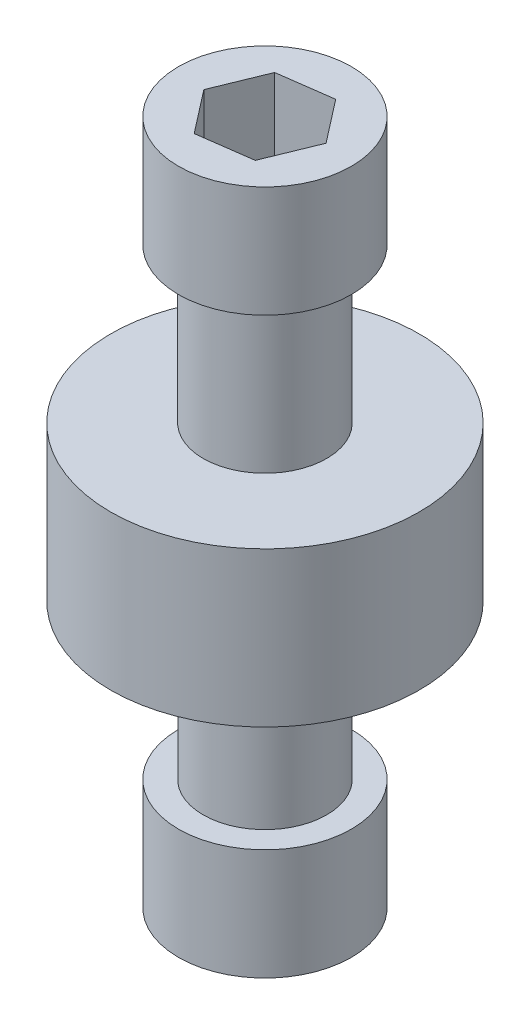
from build123d import *

# Parameters (mm, degrees)
SKETCH1_R           = 6.35
BOSS_EXTRUDE1_DEPTH = 6.35
SKETCH2_R           = 2.54
BOSS_EXTRUDE2_DEPTH = 6.35
SKETCH3_R           = 3.556
BOSS_EXTRUDE3_DEPTH = 4.572
CUT_EXTRUDE1_DEPTH  = 3.556


with BuildPart() as part:
    # Sketch1 → Boss-Extrude1 (new body)
    with BuildSketch(Plane(origin=(0, 0, 0), x_dir=(1, 0, 0), z_dir=(0, 1, 0))):
        Circle(SKETCH1_R)
    extrude(amount=BOSS_EXTRUDE1_DEPTH)

    # Sketch2 → Boss-Extrude2 (add)
    with BuildSketch(Plane(origin=(0, 6.35, 0), x_dir=(1, 0, 0), z_dir=(0, 1, 0))):
        Circle(SKETCH2_R)
    boss_extrude2 = extrude(amount=BOSS_EXTRUDE2_DEPTH)

    # Sketch3 → Boss-Extrude3 (add)
    with BuildSketch(Plane(origin=(0, 12.7, 0), x_dir=(1, 0, 0), z_dir=(0, 1, 0))):
        Circle(SKETCH3_R)
    boss_extrude3 = extrude(amount=BOSS_EXTRUDE3_DEPTH)

    # Sketch4 → Cut-Extrude1 (cut)
    with BuildSketch(Plane(origin=(0, 17.272, 0), x_dir=(1, 0, 0), z_dir=(0, 1, 0))):
        Polygon((2.212562326, 0.301992807), (0.84474772, 2.067131585), (-1.367814605, 1.765138778), (-2.212562326, -0.301992807), (-0.84474772, -2.067131585), (1.367814605, -1.765138778), align=None)
    cut_extrude1 = extrude(amount=-CUT_EXTRUDE1_DEPTH, mode=Mode.SUBTRACT)

    # Mirror1: Boss-Extrude2, Boss-Extrude3, Cut-Extrude1 across plane
    add(boss_extrude2.mirror(Plane.ZX.offset(3.175)))
    add(boss_extrude3.mirror(Plane.ZX.offset(3.175)))
    add(cut_extrude1.mirror(Plane.ZX.offset(3.175)), mode=Mode.SUBTRACT)


solid = part.part
